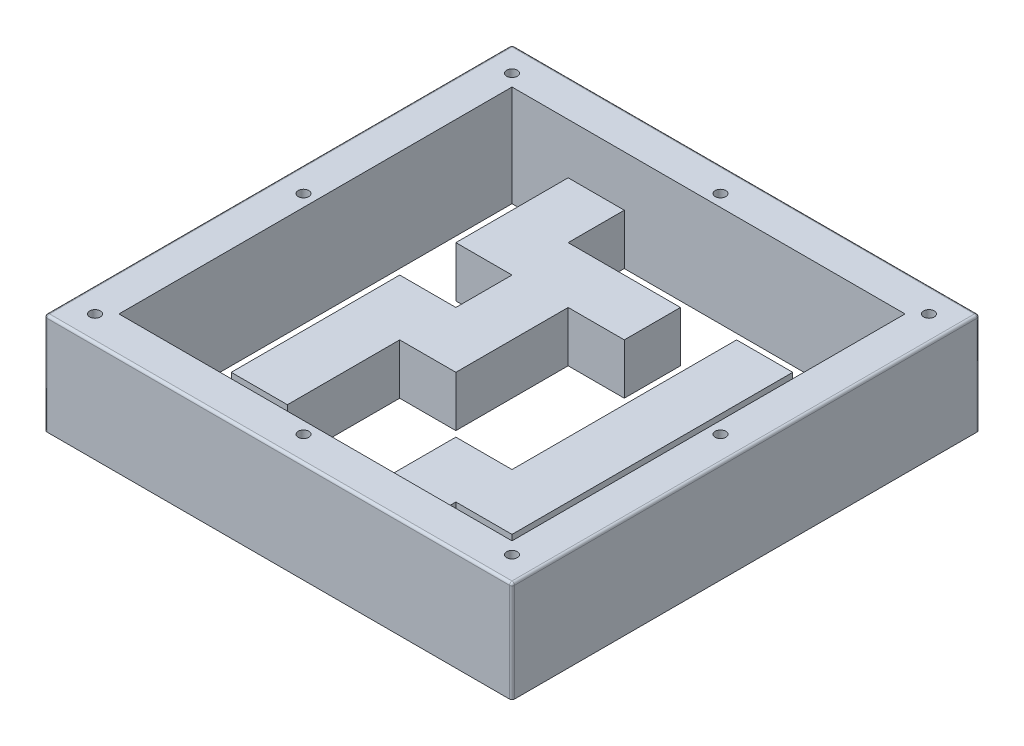
from build123d import *

# Parameters (mm, degrees)
ESQUISSE2_W             = 185
ESQUISSE2_H             = 185
BOSS_EXTRU_1_DEPTH      = 3
ESQUISSE3_W             = 185
ESQUISSE3_H             = 185
ESQUISSE3_W_2           = 155.54
ESQUISSE3_H_2           = 155.54
BOSS_EXTRU_2_DEPTH      = 40
BOSS_EXTRU_3_DEPTH      = 20
ENL_V_MAT_EXTRU_1_REACH = 5
ESQUISSE5_W             = 22.22
ESQUISSE5_H             = 22.22
ESQUISSE5_W_2           = 12.35
ESQUISSE5_H_2           = 12.35
CONG_1_R                = 1
ESQUISSE6_R             = 1.1
ENL_V_MAT_EXTRU_2_DEPTH = 44
ESQUISSE7_R             = 2.1
ENL_V_MAT_EXTRU_3_DEPTH = 44
ESQUISSE8_W             = 226.485362767
ESQUISSE8_H             = 20.409473883
ENL_V_MAT_EXTRU_4_DEPTH = 186
ESQUISSE9_R             = 2.1
ENL_V_MAT_EXTRU_5_DEPTH = 37


with BuildPart() as part:
    # Esquisse2 → Boss.-Extru.1 (new body)
    with BuildSketch(Plane(origin=(0, 0, 0), x_dir=(1, 0, 0), z_dir=(0, 1, 0))):
        Rectangle(ESQUISSE2_W, ESQUISSE2_H)
    extrude(amount=-BOSS_EXTRU_1_DEPTH)

    # Esquisse3 → Boss.-Extru.2 (add)
    with BuildSketch(Plane(origin=(0, 0, 0), x_dir=(1, 0, 0), z_dir=(0, 1, 0))):
        Rectangle(ESQUISSE3_W, ESQUISSE3_H)
        Rectangle(ESQUISSE3_W_2, ESQUISSE3_H_2, mode=Mode.SUBTRACT)
    extrude(amount=BOSS_EXTRU_2_DEPTH)

    # Esquisse4 → Boss.-Extru.3 (add)
    with BuildSketch(Plane(origin=(0, 0, 0), x_dir=(1, 0, 0), z_dir=(0, 1, 0))):
        Polygon((-55.55, 77.77), (-33.33, 77.77), (-33.33, 55.55), (11.11, 55.55), (11.11, 33.33), (-11.11, 33.33), (-11.11, -11.11), (-33.33, -11.11), (-33.33, -55.55), (-55.55, -55.55), (-55.55, 11.11), (-33.33, 11.11), (-33.33, 33.33), (-55.55, 33.33), align=None)
        Polygon((33.33, 55.55), (55.55, 55.55), (55.55, -55.55), (33.33, -55.55), (33.33, -77.77), (11.11, -77.77), (11.11, -33.33), (33.33, -33.33), align=None)
    extrude(amount=BOSS_EXTRU_3_DEPTH)

    # Esquisse5 → Enlèv. mat.-Extru.1 (cut, up to next)
    with BuildSketch(Plane(origin=(0, 0, 0), x_dir=(1, 0, 0), z_dir=(0, 1, 0)), mode=Mode.PRIVATE) as enl_v_mat_extru_1_sk1:
        with Locations((-22.22, 66.66)):
            Rectangle(ESQUISSE5_W, ESQUISSE5_H)
    enl_v_mat_extru_1_tool1 = extrude(enl_v_mat_extru_1_sk1.sketch, amount=-ENL_V_MAT_EXTRU_1_REACH, mode=Mode.PRIVATE) & part.part
    add(enl_v_mat_extru_1_tool1.solids().sort_by_distance((-22.22, 0, -66.66))[0], mode=Mode.SUBTRACT)
    # Esquisse5 → Enlèv. mat.-Extru.1 (cut, up to next)
    with BuildSketch(Plane(origin=(0, 0, 0), x_dir=(1, 0, 0), z_dir=(0, 1, 0)), mode=Mode.PRIVATE) as enl_v_mat_extru_1_sk2:
        with Locations((0, 22.22)):
            Rectangle(ESQUISSE5_W, ESQUISSE5_H)
    enl_v_mat_extru_1_tool2 = extrude(enl_v_mat_extru_1_sk2.sketch, amount=-ENL_V_MAT_EXTRU_1_REACH, mode=Mode.PRIVATE) & part.part
    add(enl_v_mat_extru_1_tool2.solids().sort_by_distance((0, 0, -22.22))[0], mode=Mode.SUBTRACT)
    # Esquisse5 → Enlèv. mat.-Extru.1 (cut, up to next)
    with BuildSketch(Plane(origin=(0, 0, 0), x_dir=(1, 0, 0), z_dir=(0, 1, 0)), mode=Mode.PRIVATE) as enl_v_mat_extru_1_sk3:
        with Locations((-27.155, -17.285)):
            Rectangle(ESQUISSE5_W_2, ESQUISSE5_H_2)
    enl_v_mat_extru_1_tool3 = extrude(enl_v_mat_extru_1_sk3.sketch, amount=-ENL_V_MAT_EXTRU_1_REACH, mode=Mode.PRIVATE) & part.part
    add(enl_v_mat_extru_1_tool3.solids().sort_by_distance((-27.155, 0, 17.285))[0], mode=Mode.SUBTRACT)
    # Esquisse5 → Enlèv. mat.-Extru.1 (cut, up to next)
    with BuildSketch(Plane(origin=(0, 0, 0), x_dir=(1, 0, 0), z_dir=(0, 1, 0)), mode=Mode.PRIVATE) as enl_v_mat_extru_1_sk4:
        with Locations((-66.66, 22.22)):
            Rectangle(ESQUISSE5_W_2, ESQUISSE5_H_2)
    enl_v_mat_extru_1_tool4 = extrude(enl_v_mat_extru_1_sk4.sketch, amount=-ENL_V_MAT_EXTRU_1_REACH, mode=Mode.PRIVATE) & part.part
    add(enl_v_mat_extru_1_tool4.solids().sort_by_distance((-66.66, 0, -22.22))[0], mode=Mode.SUBTRACT)
    # Esquisse5 → Enlèv. mat.-Extru.1 (cut, up to next)
    with BuildSketch(Plane(origin=(0, 0, 0), x_dir=(1, 0, 0), z_dir=(0, 1, 0)), mode=Mode.PRIVATE) as enl_v_mat_extru_1_sk5:
        with Locations((-66.66, -66.66)):
            Rectangle(ESQUISSE5_W_2, ESQUISSE5_H_2)
    enl_v_mat_extru_1_tool5 = extrude(enl_v_mat_extru_1_sk5.sketch, amount=-ENL_V_MAT_EXTRU_1_REACH, mode=Mode.PRIVATE) & part.part
    add(enl_v_mat_extru_1_tool5.solids().sort_by_distance((-66.66, 0, 66.66))[0], mode=Mode.SUBTRACT)
    # Esquisse5 → Enlèv. mat.-Extru.1 (cut, up to next)
    with BuildSketch(Plane(origin=(0, 0, 0), x_dir=(1, 0, 0), z_dir=(0, 1, 0)), mode=Mode.PRIVATE) as enl_v_mat_extru_1_sk6:
        with Locations((66.66, -66.66)):
            Rectangle(ESQUISSE5_W_2, ESQUISSE5_H_2)
    enl_v_mat_extru_1_tool6 = extrude(enl_v_mat_extru_1_sk6.sketch, amount=-ENL_V_MAT_EXTRU_1_REACH, mode=Mode.PRIVATE) & part.part
    add(enl_v_mat_extru_1_tool6.solids().sort_by_distance((66.66, 0, 66.66))[0], mode=Mode.SUBTRACT)
    # Esquisse5 → Enlèv. mat.-Extru.1 (cut, up to next)
    with BuildSketch(Plane(origin=(0, 0, 0), x_dir=(1, 0, 0), z_dir=(0, 1, 0)), mode=Mode.PRIVATE) as enl_v_mat_extru_1_sk7:
        with Locations((4.935, -49.375)):
            Rectangle(ESQUISSE5_W_2, ESQUISSE5_H_2)
    enl_v_mat_extru_1_tool7 = extrude(enl_v_mat_extru_1_sk7.sketch, amount=-ENL_V_MAT_EXTRU_1_REACH, mode=Mode.PRIVATE) & part.part
    add(enl_v_mat_extru_1_tool7.solids().sort_by_distance((4.935, 0, 49.375))[0], mode=Mode.SUBTRACT)

    # Congé1
    cong_1_edges = [part.edges().sort_by_distance(p)[0] for p in [
        (-92.5, 40, 0),
        (0, 40, 92.5),
        (92.5, 40, 0),
        (0, 40, -92.5),
        (-92.5, 18.5, -92.5),
        (92.5, 18.5, -92.5),
        (92.5, 18.5, 92.5),
        (-92.5, 18.5, 92.5),
    ]]
    fillet(cong_1_edges, radius=CONG_1_R)

    # Esquisse6 → Enlèv. mat.-Extru.2 (cut, through all)
    with BuildSketch(Plane(origin=(0, 40, 0), x_dir=(1, 0, 0), z_dir=(0, 1, 0))):
        with Locations(Location((-82.5, -82.5, 0), (0, 0, 270))):  # turned: the seam where the file's is
            Circle(ESQUISSE6_R)
        with Locations(Location((82.5, -82.5, 0), (0, 0, 270))):  # turned: the seam where the file's is
            Circle(ESQUISSE6_R)
        with Locations(Location((82.5, 82.5, 0), (0, 0, 270))):  # turned: the seam where the file's is
            Circle(ESQUISSE6_R)
        with Locations(Location((-82.5, 82.5, 0), (0, 0, 270))):  # turned: the seam where the file's is
            Circle(ESQUISSE6_R)
        with Locations(Location((0, 82.5, 0), (0, 0, 270))):  # turned: the seam where the file's is
            Circle(ESQUISSE6_R)
        with Locations(Location((82.5, 0, 0), (0, 0, 270))):  # turned: the seam where the file's is
            Circle(ESQUISSE6_R)
        with Locations(Location((-82.5, 0, 0), (0, 0, 270))):  # turned: the seam where the file's is
            Circle(ESQUISSE6_R)
        with Locations(Location((0, -82.5, 0), (0, 0, 270))):  # turned: the seam where the file's is
            Circle(ESQUISSE6_R)
    extrude(amount=-ENL_V_MAT_EXTRU_2_DEPTH, mode=Mode.SUBTRACT)

    # Esquisse7 → Enlèv. mat.-Extru.3 (cut, through all)
    with BuildSketch(Plane(origin=(0, 40, 0), x_dir=(1, 0, 0), z_dir=(0, 1, 0))):
        with Locations(Location((-82.5, -82.5, 0), (0, 0, 270))):  # turned: the seam where the file's is
            Circle(ESQUISSE7_R)
        with Locations(Location((-82.5, 82.5, 0), (0, 0, 270))):  # turned: the seam where the file's is
            Circle(ESQUISSE7_R)
        with Locations(Location((82.5, 82.5, 0), (0, 0, 270))):  # turned: the seam where the file's is
            Circle(ESQUISSE7_R)
        with Locations(Location((82.5, -82.5, 0), (0, 0, 270))):  # turned: the seam where the file's is
            Circle(ESQUISSE7_R)
    extrude(amount=-ENL_V_MAT_EXTRU_3_DEPTH, mode=Mode.SUBTRACT)

    # Esquisse8 → Enlèv. mat.-Extru.4 (cut, through all)
    with BuildSketch(Plane.XY.offset(92.5)):
        with Locations((0.829347629, -10.204736942)):
            Rectangle(ESQUISSE8_W, ESQUISSE8_H)
    extrude(amount=-ENL_V_MAT_EXTRU_4_DEPTH, mode=Mode.SUBTRACT)

    # Esquisse9 → Enlèv. mat.-Extru.5 (cut)
    with BuildSketch(Plane(origin=(0, 40, 0), x_dir=(1, 0, 0), z_dir=(0, 1, 0))):
        with Locations(Location((0, 82.5, 0), (0, 0, 270))):  # turned: the seam where the file's is
            Circle(ESQUISSE9_R)
        with Locations(Location((82.5, 0, 0), (0, 0, 270))):  # turned: the seam where the file's is
            Circle(ESQUISSE9_R)
        with Locations(Location((0, -82.5, 0), (0, 0, 270))):  # turned: the seam where the file's is
            Circle(ESQUISSE9_R)
        with Locations(Location((-82.5, 0, 0), (0, 0, 270))):  # turned: the seam where the file's is
            Circle(ESQUISSE9_R)
    extrude(amount=-ENL_V_MAT_EXTRU_5_DEPTH, mode=Mode.SUBTRACT)


solid = part.part
